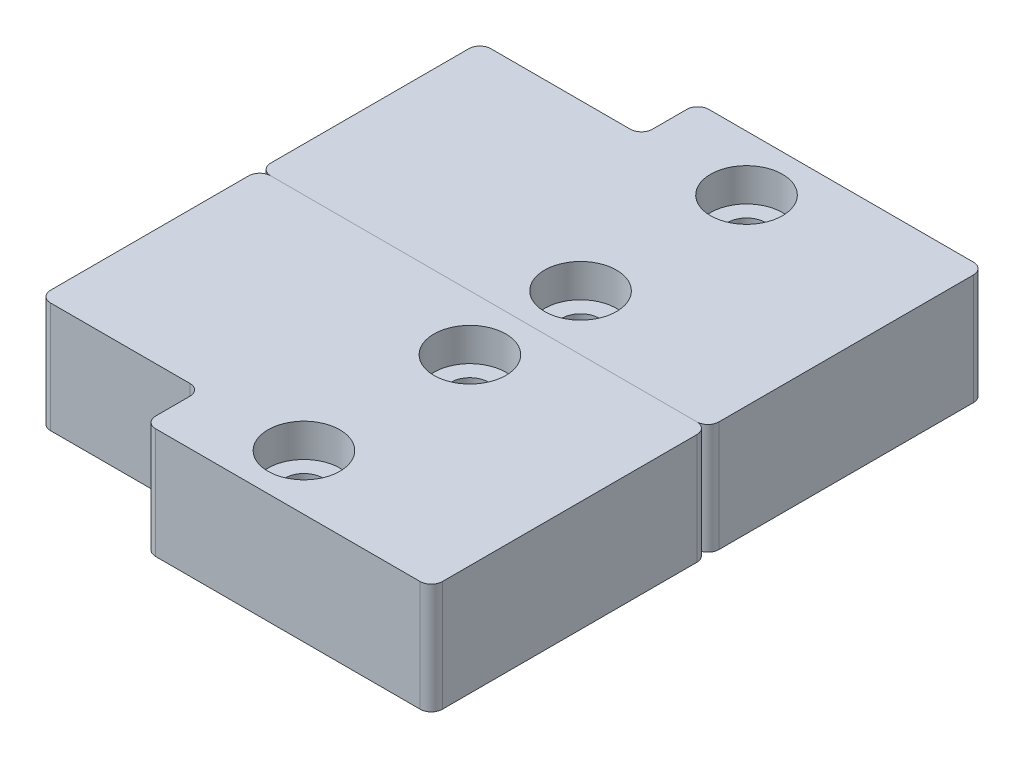
from build123d import *

# Parameters (mm, degrees)
BOSS_EXTRUDE1_DEPTH            = 10
FILLET1_R                      = 1
CBORE_FOR_M3_SHCS1_D           = 3.4
CBORE_FOR_M3_SHCS1_DEPTH       = 10
CBORE_FOR_M3_SHCS1_CBORE_D     = 6.5
CBORE_FOR_M3_SHCS1_CBORE_DEPTH = 3


with BuildPart() as part:
    # Sketch1 → Boss-Extrude1 (new body)
    with BuildSketch(Plane(origin=(0, 0, 0), x_dir=(1, 0, 0), z_dir=(0, 1, 0))):
        Polygon((0, 0), (40.51, 0), (40.51, 25), (14.6, 25), (14.6, 19.9), (0, 19.9), align=None)
    extrude(amount=BOSS_EXTRUDE1_DEPTH)

    # Fillet1
    fillet1_edges = [part.edges().sort_by_distance(p)[0] for p in [
        (0, 5, -19.9),
        (14.6, 5, -19.9),
        (14.6, 5, -25),
        (40.51, 5, -25),
        (40.51, 5, 0),
        (0, 5, 0),
    ]]
    fillet(fillet1_edges, radius=FILLET1_R)

    # CBORE for M3 SHCS1
    with Locations(Plane(origin=(0, 10, 0), x_dir=(1, 0, 0), z_dir=(0, 1, 0))):
        with Locations((24, 20), (24, 5)):
            CounterBoreHole(CBORE_FOR_M3_SHCS1_D / 2, CBORE_FOR_M3_SHCS1_CBORE_D / 2, CBORE_FOR_M3_SHCS1_CBORE_DEPTH, depth=CBORE_FOR_M3_SHCS1_DEPTH)


with BuildPart() as body_2:
    # Mirror1: mirrored copy
    add(part.part.mirror(Plane(origin=(0, 10, 0), x_dir=(1, 0, 0), z_dir=(0, 0, -1))))


solid = Compound([part.part, body_2.part])
